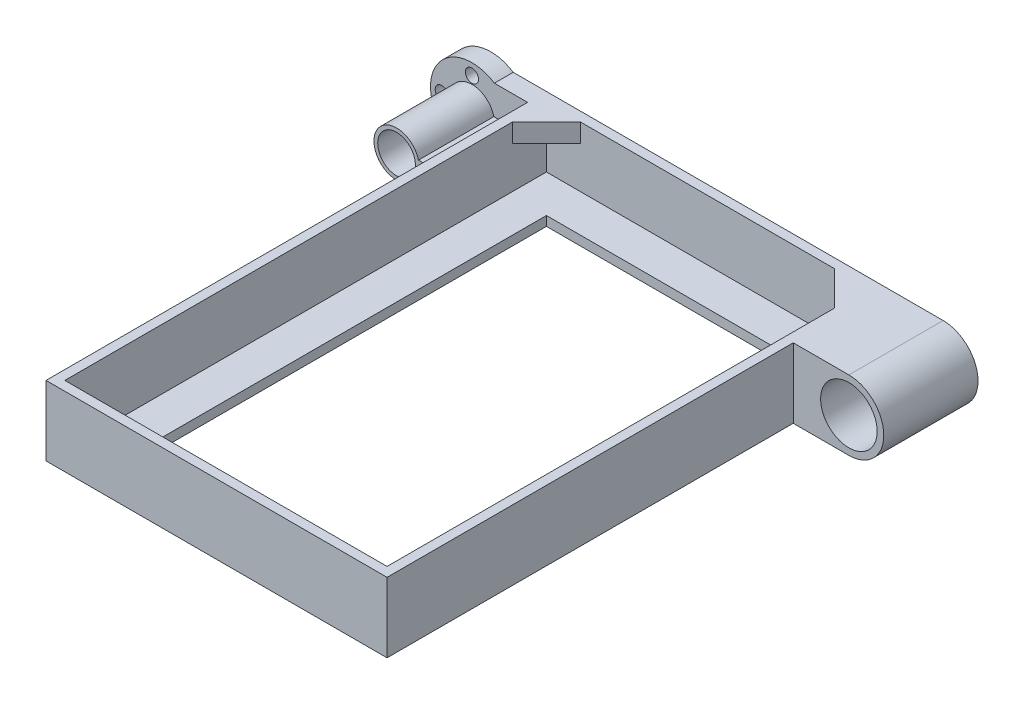
from build123d import *

# Parameters (mm, degrees)
SKETCH1_W           = 90.48
SKETCH1_H           = 132.76
SKETCH1_W_2         = 85.48
SKETCH1_H_2         = 127.76
BOSS_EXTRUDE1_DEPTH = 16
SKETCH2_W           = 90.48
SKETCH2_H           = 132.76
BOSS_EXTRUDE2_DEPTH = 2.5
SKETCH3_R           = 7.5
BOSS_EXTRUDE3_DEPTH = 25
SKETCH4_R           = 7.5
SKETCH4_R_2         = 5
BOSS_EXTRUDE4_DEPTH = 25
SKETCH5_R           = 11
SKETCH5_R_2         = 5
BOSS_EXTRUDE5_DEPTH = 5
SKETCH7_R           = 5
CUT_EXTRUDE2_DEPTH  = 20
CUT_EXTRUDE3_REACH  = 134.76
SKETCH8_R           = 1.75
BOSS_EXTRUDE6_DEPTH = 5
SKETCH10_W          = 65.48
SKETCH10_H          = 107.76
CUT_EXTRUDE4_DEPTH  = 5.25


with BuildPart() as part:
    # Sketch1 → Boss-Extrude1 (new body)
    with BuildSketch(Plane(origin=(0, 0, 0), x_dir=(1, 0, 0), z_dir=(0, 1, 0))):
        Rectangle(SKETCH1_W, SKETCH1_H)
        Rectangle(SKETCH1_W_2, SKETCH1_H_2, mode=Mode.SUBTRACT)
    extrude(amount=BOSS_EXTRUDE1_DEPTH)

    # Sketch2 → Boss-Extrude2 (add)
    with BuildSketch(Plane.XZ):
        Rectangle(SKETCH2_W, SKETCH2_H)
    extrude(amount=BOSS_EXTRUDE2_DEPTH)

    # Sketch3 → Boss-Extrude3 (add)
    with BuildSketch(Plane(origin=(0, 0, -66.38), x_dir=(-1, 0, 0), z_dir=(0, 0, -1))):
        with BuildLine():
            Line((-45.24, 16), (-60, 16))
            ThreePointArc((-60, 16), (-69.25, 6.75), (-60, -2.5))
            Line((-60, -2.5), (-45.24, -2.5))
            Line((-45.24, -2.5), (-45.24, 16))
        make_face()
        with Locations((-60, 6.75)):
            Circle(SKETCH3_R, mode=Mode.SUBTRACT)
    boss_extrude3 = extrude(amount=-BOSS_EXTRUDE3_DEPTH)

    # Mirror1: Boss-Extrude3 across plane
    add(boss_extrude3.mirror(Plane(origin=(0, 0, 0), x_dir=(0, 0, 1), z_dir=(1, 0, 0))))

    # Sketch4 → Boss-Extrude4 (add)
    with BuildSketch(Plane(origin=(0, 0, -66.38), x_dir=(-1, 0, 0), z_dir=(0, 0, -1))):
        with Locations((60, 6.75)):
            Circle(SKETCH4_R)
        with Locations((60, 6.75)):
            Circle(SKETCH4_R_2, mode=Mode.SUBTRACT)
    extrude(amount=-BOSS_EXTRUDE4_DEPTH)

    # Sketch5 → Boss-Extrude5 (add)
    with BuildSketch(Plane(origin=(0, 0, -66.38), x_dir=(-1, 0, 0), z_dir=(0, 0, -1))):
        with Locations((60, 6.75)):
            Circle(SKETCH5_R)
        with Locations((60, 6.75)):
            Circle(SKETCH5_R_2, mode=Mode.SUBTRACT)
    extrude(amount=-BOSS_EXTRUDE5_DEPTH)

    # Sketch7 → Cut-Extrude2 (cut)
    with BuildSketch(Plane.XY.offset(-41.38)):
        with Locations((-60, 6.75)):
            Circle(SKETCH7_R)
        with BuildLine():
            Line((-45.24, -2.5), (-60, -2.5))
            ThreePointArc((-60, -2.5), (-69.25, 6.75), (-60, 16))
            Line((-60, 16), (-45.24, 16))
            Line((-45.24, 16), (-45.24, 8.25))
            Line((-45.24, 8.25), (-54.190524981, 8.25))
            ThreePointArc((-54.190524981, 8.25), (-66, 6.75), (-54.190524981, 5.25))
            Line((-54.190524981, 5.25), (-45.24, 5.25))
            Line((-45.24, 5.25), (-45.24, -2.5))
        make_face()
    extrude(amount=-CUT_EXTRUDE2_DEPTH, mode=Mode.SUBTRACT)

    # Sketch8 → Cut-Extrude3 (cut, up to next)
    with BuildSketch(Plane(origin=(0, 0, -66.38), x_dir=(-1, 0, 0), z_dir=(0, 0, -1)), mode=Mode.PRIVATE) as cut_extrude3_sk1:
        with Locations((60, 14.75)):
            Circle(SKETCH8_R)
    cut_extrude3_tool1 = extrude(cut_extrude3_sk1.sketch, amount=-CUT_EXTRUDE3_REACH, mode=Mode.PRIVATE) & part.part
    add(cut_extrude3_tool1.solids().sort_by_distance((-60, 14.75, -66.38))[0], mode=Mode.SUBTRACT)
    # Sketch8 → Cut-Extrude3 (cut, up to next)
    with BuildSketch(Plane(origin=(0, 0, -66.38), x_dir=(-1, 0, 0), z_dir=(0, 0, -1)), mode=Mode.PRIVATE) as cut_extrude3_sk2:
        with Locations((68, 6.75)):
            Circle(SKETCH8_R)
    cut_extrude3_tool2 = extrude(cut_extrude3_sk2.sketch, amount=-CUT_EXTRUDE3_REACH, mode=Mode.PRIVATE) & part.part
    add(cut_extrude3_tool2.solids().sort_by_distance((-68, 6.75, -66.38))[0], mode=Mode.SUBTRACT)
    # Sketch8 → Cut-Extrude3 (cut, up to next)
    with BuildSketch(Plane(origin=(0, 0, -66.38), x_dir=(-1, 0, 0), z_dir=(0, 0, -1)), mode=Mode.PRIVATE) as cut_extrude3_sk3:
        with Locations((60, -1.25)):
            Circle(SKETCH8_R)
    cut_extrude3_tool3 = extrude(cut_extrude3_sk3.sketch, amount=-CUT_EXTRUDE3_REACH, mode=Mode.PRIVATE) & part.part
    add(cut_extrude3_tool3.solids().sort_by_distance((-60, -1.25, -66.38))[0], mode=Mode.SUBTRACT)

    # Sketch9 → Boss-Extrude6 (add)
    with BuildSketch(Plane(origin=(0, 16, 0), x_dir=(1, 0, 0), z_dir=(0, 1, 0))):
        Polygon((33.74, 63.88), (42.74, 54.88), (42.74, 63.88), align=None)
        Polygon((-42.74, 54.88), (-33.74, 63.88), (-42.74, 63.88), align=None)
    extrude(amount=-BOSS_EXTRUDE6_DEPTH)

    # Sketch10 → Cut-Extrude4 (cut, through all)
    with BuildSketch(Plane(origin=(0, 0, 0), x_dir=(1, 0, 0), z_dir=(0, 1, 0))):
        Rectangle(SKETCH10_W, SKETCH10_H)
    extrude(amount=-CUT_EXTRUDE4_DEPTH, mode=Mode.SUBTRACT)


solid = part.part
